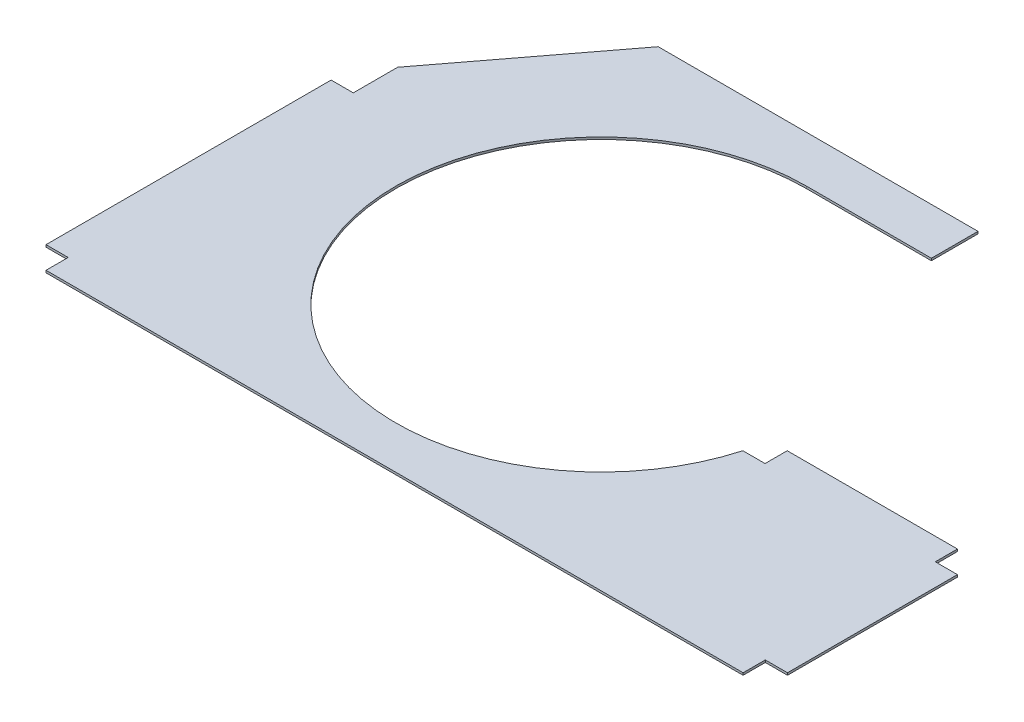
from build123d import *

# Parameters (mm, degrees)
BOSS_EXTRUDE1_DEPTH = 2


with BuildPart() as part:
    # Sketch1 → Boss-Extrude1 (new body)
    with BuildSketch(Plane(origin=(0, 0, 0), x_dir=(1, 0, 0), z_dir=(0, 1, 0))):
        with BuildLine():
            Line((0, 0), (20, 0))
            Line((20, 0), (20, -20))
            Line((20, -20), (648.38, -20))
            Line((648.38, -20), (648.38, 0))
            Line((648.38, 0), (668.38, 0))
            Line((668.38, 0), (668.38, 153.21))
            Line((668.38, 153.21), (648.38, 153.21))
            Line((648.38, 153.21), (648.38, 173.21))
            Line((648.38, 173.21), (494.944943633, 173.21))
            Line((494.944943633, 173.21), (494.944943633, 153.21))
            Line((494.944943633, 153.21), (474.944943633, 153.21))
            ThreePointArc((474.944943633, 153.21), (149.385371312, 91.815127637), (296.9, 388.45935867))
            Line((296.9, 388.45935867), (409.658335612, 388.45935867))
            Line((409.658335612, 388.45935867), (409.658335612, 430.45935867))
            Line((409.658335612, 430.45935867), (121.389532072, 430.45935867))
            Line((121.389532072, 430.45935867), (20, 297))
            Line((20, 297), (20, 257))
            Line((20, 257), (0, 257))
            Line((0, 257), (0, 0))
        make_face()
    extrude(amount=BOSS_EXTRUDE1_DEPTH)


solid = part.part
